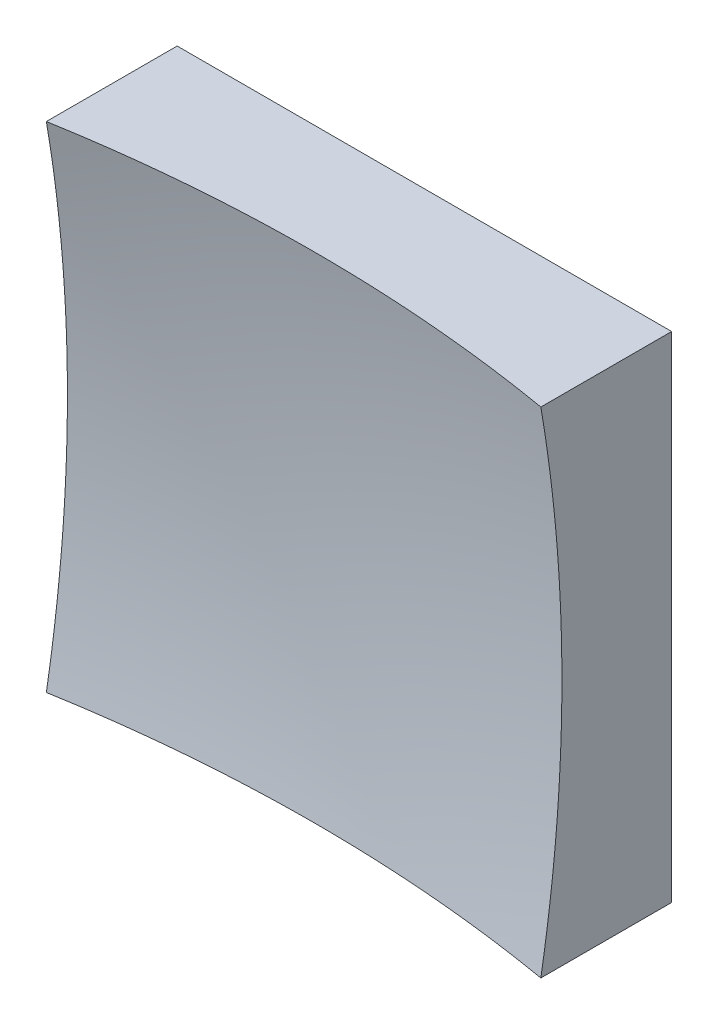
from build123d import *

# Parameters (mm, degrees)
SKETCH_1_W      = 50
SKETCH_1_H      = 50
EXTRUDE_1_DEPTH = 50


with BuildPart() as part:
    # 草图1 → 凸台-拉伸1 (new body)
    with BuildSketch(Plane.XY):
        Rectangle(SKETCH_1_W, SKETCH_1_H)
    extrude(amount=EXTRUDE_1_DEPTH)

    # 草图2 → 切除-旋转2 (revolve, cut)
    with BuildSketch(Plane(origin=(0, 0, 0), x_dir=(1, 0, 0), z_dir=(0, 1, 0))):
        with BuildLine():
            Line((146.226819272, -125.567720305), (0, -125.567720305))
            Line((0, -125.567720305), (0, -9))
            ThreePointArc((0, -9), (93.501759464, -41.70796712), (146.226819272, -125.567720305))
        make_face()
    revolve(axis=Axis((0, 0, 125.567720305), (0, 0, -1)), mode=Mode.SUBTRACT)


solid = part.part
